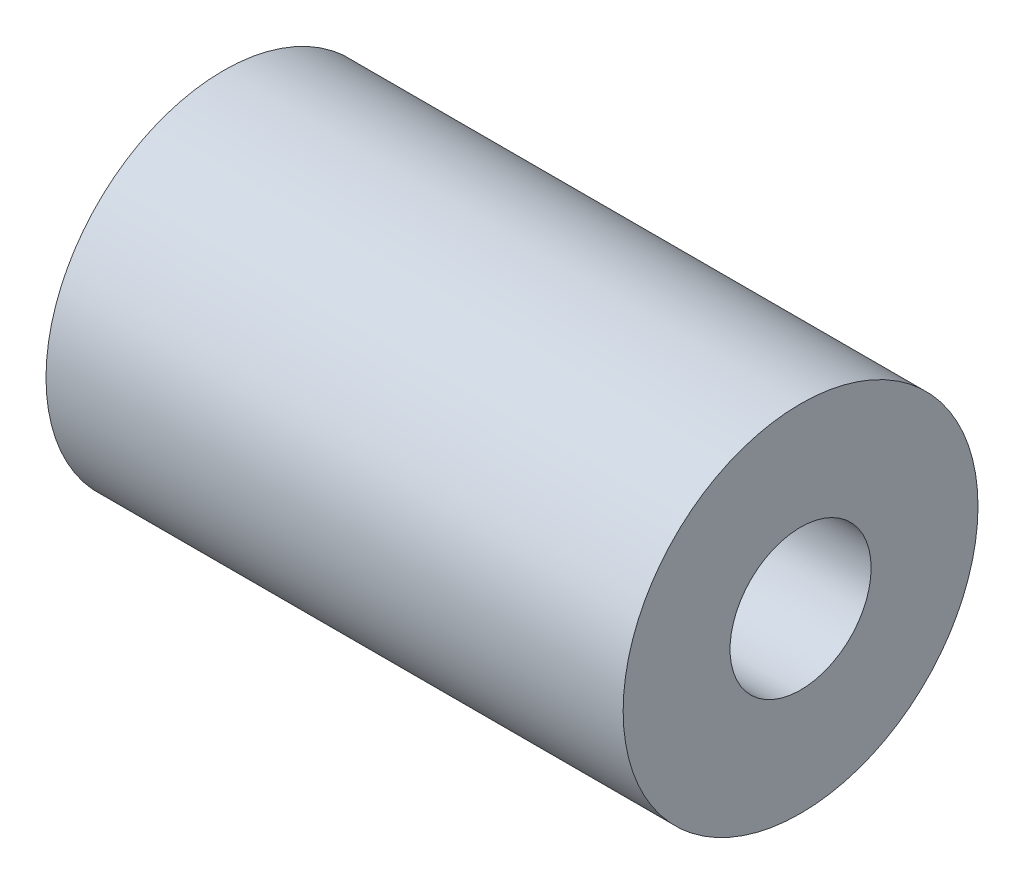
from build123d import *

# Parameters (mm, degrees)
SKETCH_1_R      = 4.15
SKETCH_1_R_2    = 1.65
EXTRUDE_1_DEPTH = 13.5


with BuildPart() as part:
    # 草图1 → 凸台-拉伸1 (new body)
    with BuildSketch(Plane(origin=(0, 0, 0), x_dir=(0, 0, -1), z_dir=(1, 0, 0))):
        Circle(SKETCH_1_R)
        Circle(SKETCH_1_R_2, mode=Mode.SUBTRACT)
    extrude(amount=EXTRUDE_1_DEPTH)


solid = part.part
